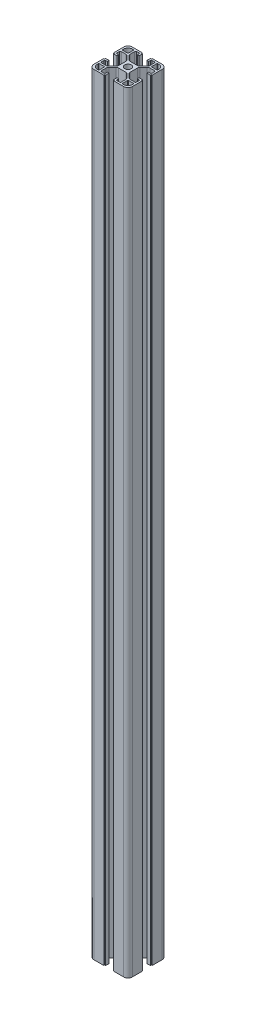
from build123d import *

# Parameters (mm, degrees)
BOSS_EXTRUDE1_DEPTH = 800


with BuildPart() as part:
    # Sketch1 → Boss-Extrude1 (new body)
    with BuildSketch(Plane(origin=(0, 0, 0), x_dir=(1, 0, 0), z_dir=(0, 1, 0))):
        with BuildLine():
            Line((84.170223908, 31.720417041), (84.170223908, 42.120417041))
            Line((84.170223908, 42.120417041), (83.570223908, 42.120417041))
            ThreePointArc((83.570223908, 42.120417041), (83.428802552, 42.178995685), (83.370223908, 42.320417041))
            Line((83.370223908, 42.320417041), (83.370223908, 42.920417041))
            ThreePointArc((83.370223908, 42.920417041), (83.311645264, 43.061838398), (83.170223908, 43.120417041))
            Line((83.170223908, 43.120417041), (79.670223908, 43.120417041))
            Line((79.670223908, 43.120417041), (79.670223908, 41.320417041))
            Line((79.670223908, 41.320417041), (81.370223908, 41.320417041))
            ThreePointArc((81.370223908, 41.320417041), (82.077330689, 41.027523823), (82.370223908, 40.320417041))
            Line((82.370223908, 40.320417041), (82.370223908, 37.970417041))
            ThreePointArc((82.370223908, 37.970417041), (82.077330689, 37.26331026), (81.370223908, 36.970417041))
            Line((81.370223908, 36.970417041), (76.723524767, 36.970417041))
            ThreePointArc((76.723524767, 36.970417041), (75.57547447, 37.198778444), (74.602204423, 37.849096698))
            Line((74.602204423, 37.849096698), (71.048903564, 41.402397557))
            ThreePointArc((71.048903564, 41.402397557), (70.39858531, 42.375667603), (70.170223908, 43.5237179))
            Line((70.170223908, 43.5237179), (70.170223908, 50.917116183))
            ThreePointArc((70.170223908, 50.917116183), (70.39858531, 52.06516648), (71.048903564, 53.038436526))
            Line((71.048903564, 53.038436526), (74.602204423, 56.591737385))
            ThreePointArc((74.602204423, 56.591737385), (75.57547447, 57.242055639), (76.723524767, 57.470417041))
            Line((76.723524767, 57.470417041), (81.370223908, 57.470417041))
            ThreePointArc((81.370223908, 57.470417041), (82.077330689, 57.177523823), (82.370223908, 56.470417041))
            Line((82.370223908, 56.470417041), (82.370223908, 54.120417041))
            ThreePointArc((82.370223908, 54.120417041), (82.077330689, 53.41331026), (81.370223908, 53.120417041))
            Line((81.370223908, 53.120417041), (79.670223908, 53.120417041))
            Line((79.670223908, 53.120417041), (79.670223908, 51.320417041))
            Line((79.670223908, 51.320417041), (83.170223908, 51.320417041))
            ThreePointArc((83.170223908, 51.320417041), (83.311645264, 51.378995685), (83.370223908, 51.520417041))
            Line((83.370223908, 51.520417041), (83.370223908, 52.120417041))
            ThreePointArc((83.370223908, 52.120417041), (83.428802552, 52.261838398), (83.570223908, 52.320417041))
            Line((83.570223908, 52.320417041), (84.170223908, 52.320417041))
            Line((84.170223908, 52.320417041), (84.170223908, 62.720417041))
            ThreePointArc((84.170223908, 62.720417041), (82.852204423, 65.902397557), (79.670223908, 67.220417041))
            Line((79.670223908, 67.220417041), (69.470223908, 67.220417041))
            ThreePointArc((69.470223908, 67.220417041), (69.328802552, 67.161838398), (69.270223908, 67.020417041))
            Line((69.270223908, 67.020417041), (69.270223908, 66.620417041))
            ThreePointArc((69.270223908, 66.620417041), (69.211645264, 66.478995685), (69.070223908, 66.420417041))
            Line((69.070223908, 66.420417041), (68.470223908, 66.420417041))
            ThreePointArc((68.470223908, 66.420417041), (68.328802552, 66.361838398), (68.270223908, 66.220417041))
            Line((68.270223908, 66.220417041), (68.270223908, 62.720417041))
            Line((68.270223908, 62.720417041), (70.070223908, 62.720417041))
            Line((70.070223908, 62.720417041), (70.070223908, 64.420417041))
            ThreePointArc((70.070223908, 64.420417041), (70.363117127, 65.127523823), (71.070223908, 65.420417041))
            Line((71.070223908, 65.420417041), (73.420223908, 65.420417041))
            ThreePointArc((73.420223908, 65.420417041), (74.127330689, 65.127523823), (74.420223908, 64.420417041))
            Line((74.420223908, 64.420417041), (74.420223908, 59.7737179))
            ThreePointArc((74.420223908, 59.7737179), (74.191862505, 58.625667603), (73.541544251, 57.652397557))
            Line((73.541544251, 57.652397557), (69.988243393, 54.099096698))
            ThreePointArc((69.988243393, 54.099096698), (69.014973346, 53.448778444), (67.866923049, 53.220417041))
            Line((67.866923049, 53.220417041), (60.473524767, 53.220417041))
            ThreePointArc((60.473524767, 53.220417041), (59.32547447, 53.448778444), (58.352204423, 54.099096698))
            Line((58.352204423, 54.099096698), (54.798903564, 57.652397557))
            ThreePointArc((54.798903564, 57.652397557), (54.14858531, 58.625667603), (53.920223908, 59.7737179))
            Line((53.920223908, 59.7737179), (53.920223908, 64.420417041))
            ThreePointArc((53.920223908, 64.420417041), (54.213117127, 65.127523823), (54.920223908, 65.420417041))
            Line((54.920223908, 65.420417041), (57.270223908, 65.420417041))
            ThreePointArc((57.270223908, 65.420417041), (57.977330689, 65.127523823), (58.270223908, 64.420417041))
            Line((58.270223908, 64.420417041), (58.270223908, 62.720417041))
            Line((58.270223908, 62.720417041), (60.070223908, 62.720417041))
            Line((60.070223908, 62.720417041), (60.070223908, 66.220417041))
            ThreePointArc((60.070223908, 66.220417041), (60.011645264, 66.361838398), (59.870223908, 66.420417041))
            Line((59.870223908, 66.420417041), (59.270223908, 66.420417041))
            ThreePointArc((59.270223908, 66.420417041), (59.128802552, 66.478995685), (59.070223908, 66.620417041))
            Line((59.070223908, 66.620417041), (59.070223908, 67.020417041))
            ThreePointArc((59.070223908, 67.020417041), (59.011645264, 67.161838398), (58.870223908, 67.220417041))
            Line((58.870223908, 67.220417041), (48.670223908, 67.220417041))
            ThreePointArc((48.670223908, 67.220417041), (45.488243393, 65.902397557), (44.170223908, 62.720417041))
            Line((44.170223908, 62.720417041), (44.170223908, 52.320417041))
            Line((44.170223908, 52.320417041), (44.770223908, 52.320417041))
            ThreePointArc((44.770223908, 52.320417041), (44.911645264, 52.261838398), (44.970223908, 52.120417041))
            Line((44.970223908, 52.120417041), (44.970223908, 51.520417041))
            ThreePointArc((44.970223908, 51.520417041), (45.028802552, 51.378995685), (45.170223908, 51.320417041))
            Line((45.170223908, 51.320417041), (48.670223908, 51.320417041))
            Line((48.670223908, 51.320417041), (48.670223908, 53.120417041))
            Line((48.670223908, 53.120417041), (46.970223908, 53.120417041))
            ThreePointArc((46.970223908, 53.120417041), (46.263117127, 53.41331026), (45.970223908, 54.120417041))
            Line((45.970223908, 54.120417041), (45.970223908, 56.470417041))
            ThreePointArc((45.970223908, 56.470417041), (46.263117127, 57.177523823), (46.970223908, 57.470417041))
            Line((46.970223908, 57.470417041), (51.616923049, 57.470417041))
            ThreePointArc((51.616923049, 57.470417041), (52.764973346, 57.242055639), (53.738243393, 56.591737385))
            Line((53.738243393, 56.591737385), (57.291544251, 53.038436526))
            ThreePointArc((57.291544251, 53.038436526), (57.941862505, 52.06516648), (58.170223908, 50.917116183))
            Line((58.170223908, 50.917116183), (58.170223908, 43.5237179))
            ThreePointArc((58.170223908, 43.5237179), (57.941862505, 42.375667603), (57.291544251, 41.402397557))
            Line((57.291544251, 41.402397557), (53.738243393, 37.849096698))
            ThreePointArc((53.738243393, 37.849096698), (52.764973346, 37.198778444), (51.616923049, 36.970417041))
            Line((51.616923049, 36.970417041), (46.970223908, 36.970417041))
            ThreePointArc((46.970223908, 36.970417041), (46.263117127, 37.26331026), (45.970223908, 37.970417041))
            Line((45.970223908, 37.970417041), (45.970223908, 40.320417041))
            ThreePointArc((45.970223908, 40.320417041), (46.263117127, 41.027523823), (46.970223908, 41.320417041))
            Line((46.970223908, 41.320417041), (48.670223908, 41.320417041))
            Line((48.670223908, 41.320417041), (48.670223908, 43.120417041))
            Line((48.670223908, 43.120417041), (45.170223908, 43.120417041))
            ThreePointArc((45.170223908, 43.120417041), (45.028802552, 43.061838398), (44.970223908, 42.920417041))
            Line((44.970223908, 42.920417041), (44.970223908, 42.320417041))
            ThreePointArc((44.970223908, 42.320417041), (44.911645264, 42.178995685), (44.770223908, 42.120417041))
            Line((44.770223908, 42.120417041), (44.170223908, 42.120417041))
            Line((44.170223908, 42.120417041), (44.170223908, 31.720417041))
            ThreePointArc((44.170223908, 31.720417041), (45.488243393, 28.538436526), (48.670223908, 27.220417041))
            Line((48.670223908, 27.220417041), (59.070223908, 27.220417041))
            Line((59.070223908, 27.220417041), (59.070223908, 27.820417041))
            ThreePointArc((59.070223908, 27.820417041), (59.128802552, 27.961838398), (59.270223908, 28.020417041))
            Line((59.270223908, 28.020417041), (59.870223908, 28.020417041))
            ThreePointArc((59.870223908, 28.020417041), (60.011645264, 28.078995685), (60.070223908, 28.220417041))
            Line((60.070223908, 28.220417041), (60.070223908, 31.720417041))
            Line((60.070223908, 31.720417041), (58.270223908, 31.720417041))
            Line((58.270223908, 31.720417041), (58.270223908, 30.020417041))
            ThreePointArc((58.270223908, 30.020417041), (57.977330689, 29.31331026), (57.270223908, 29.020417041))
            Line((57.270223908, 29.020417041), (54.920223908, 29.020417041))
            ThreePointArc((54.920223908, 29.020417041), (54.213117127, 29.31331026), (53.920223908, 30.020417041))
            Line((53.920223908, 30.020417041), (53.920223908, 34.667116183))
            ThreePointArc((53.920223908, 34.667116183), (54.14858531, 35.81516648), (54.798903564, 36.788436526))
            Line((54.798903564, 36.788436526), (58.352204423, 40.341737385))
            ThreePointArc((58.352204423, 40.341737385), (59.32547447, 40.992055639), (60.473524767, 41.220417041))
            Line((60.473524767, 41.220417041), (67.866923049, 41.220417041))
            ThreePointArc((67.866923049, 41.220417041), (69.014973346, 40.992055639), (69.988243393, 40.341737385))
            Line((69.988243393, 40.341737385), (73.541544251, 36.788436526))
            ThreePointArc((73.541544251, 36.788436526), (74.191862505, 35.81516648), (74.420223908, 34.667116183))
            Line((74.420223908, 34.667116183), (74.420223908, 30.020417041))
            ThreePointArc((74.420223908, 30.020417041), (74.127330689, 29.31331026), (73.420223908, 29.020417041))
            Line((73.420223908, 29.020417041), (71.070223908, 29.020417041))
            ThreePointArc((71.070223908, 29.020417041), (70.363117127, 29.31331026), (70.070223908, 30.020417041))
            Line((70.070223908, 30.020417041), (70.070223908, 31.720417041))
            Line((70.070223908, 31.720417041), (68.270223908, 31.720417041))
            Line((68.270223908, 31.720417041), (68.270223908, 28.220417041))
            ThreePointArc((68.270223908, 28.220417041), (68.328802552, 28.078995685), (68.470223908, 28.020417041))
            Line((68.470223908, 28.020417041), (69.070223908, 28.020417041))
            ThreePointArc((69.070223908, 28.020417041), (69.211645264, 27.961838398), (69.270223908, 27.820417041))
            Line((69.270223908, 27.820417041), (69.270223908, 27.220417041))
            Line((69.270223908, 27.220417041), (79.670223908, 27.220417041))
            ThreePointArc((79.670223908, 27.220417041), (82.852204423, 28.538436526), (84.170223908, 31.720417041))
        make_face()
        with BuildLine():
            Line((82.370223908, 34.670417041), (82.370223908, 33.520417041))
            ThreePointArc((82.370223908, 33.520417041), (81.052204423, 30.338436526), (77.870223908, 29.020417041))
            Line((77.870223908, 29.020417041), (76.720223908, 29.020417041))
            ThreePointArc((76.720223908, 29.020417041), (76.366670517, 29.166863651), (76.220223908, 29.520417041))
            Line((76.220223908, 29.520417041), (76.220223908, 34.670417041))
            ThreePointArc((76.220223908, 34.670417041), (76.366670517, 35.023970432), (76.720223908, 35.170417041))
            Line((76.720223908, 35.170417041), (81.870223908, 35.170417041))
            ThreePointArc((81.870223908, 35.170417041), (82.223777298, 35.023970432), (82.370223908, 34.670417041))
        make_face(mode=Mode.SUBTRACT)
        with BuildLine():
            Line((51.620223908, 29.020417041), (50.470223908, 29.020417041))
            ThreePointArc((50.470223908, 29.020417041), (47.288243393, 30.338436526), (45.970223908, 33.520417041))
            Line((45.970223908, 33.520417041), (45.970223908, 34.670417041))
            ThreePointArc((45.970223908, 34.670417041), (46.116670517, 35.023970432), (46.470223908, 35.170417041))
            Line((46.470223908, 35.170417041), (51.620223908, 35.170417041))
            ThreePointArc((51.620223908, 35.170417041), (51.973777298, 35.023970432), (52.120223908, 34.670417041))
            Line((52.120223908, 34.670417041), (52.120223908, 29.520417041))
            ThreePointArc((52.120223908, 29.520417041), (51.973777298, 29.166863651), (51.620223908, 29.020417041))
        make_face(mode=Mode.SUBTRACT)
        with BuildLine():
            Line((45.970223908, 59.770417041), (45.970223908, 60.920417041))
            ThreePointArc((45.970223908, 60.920417041), (47.288243393, 64.102397557), (50.470223908, 65.420417041))
            Line((50.470223908, 65.420417041), (51.620223908, 65.420417041))
            ThreePointArc((51.620223908, 65.420417041), (51.973777298, 65.273970432), (52.120223908, 64.920417041))
            Line((52.120223908, 64.920417041), (52.120223908, 59.770417041))
            ThreePointArc((52.120223908, 59.770417041), (51.973777298, 59.416863651), (51.620223908, 59.270417041))
            Line((51.620223908, 59.270417041), (46.470223908, 59.270417041))
            ThreePointArc((46.470223908, 59.270417041), (46.116670517, 59.416863651), (45.970223908, 59.770417041))
        make_face(mode=Mode.SUBTRACT)
        with BuildLine():
            Line((76.720223908, 65.420417041), (77.870223908, 65.420417041))
            ThreePointArc((77.870223908, 65.420417041), (81.052204423, 64.102397557), (82.370223908, 60.920417041))
            Line((82.370223908, 60.920417041), (82.370223908, 59.770417041))
            ThreePointArc((82.370223908, 59.770417041), (82.223777298, 59.416863651), (81.870223908, 59.270417041))
            Line((81.870223908, 59.270417041), (76.720223908, 59.270417041))
            ThreePointArc((76.720223908, 59.270417041), (76.366670517, 59.416863651), (76.220223908, 59.770417041))
            Line((76.220223908, 59.770417041), (76.220223908, 64.920417041))
            ThreePointArc((76.220223908, 64.920417041), (76.366670517, 65.273970432), (76.720223908, 65.420417041))
        make_face(mode=Mode.SUBTRACT)
        with BuildLine():
            ThreePointArc((60.770223908, 47.220417041), (64.170223908, 43.820417041), (67.570223908, 47.220417041))
            ThreePointArc((67.570223908, 47.220417041), (64.170223908, 50.620417041), (60.770223908, 47.220417041))
        make_face(mode=Mode.SUBTRACT)
    extrude(amount=BOSS_EXTRUDE1_DEPTH)


solid = part.part
